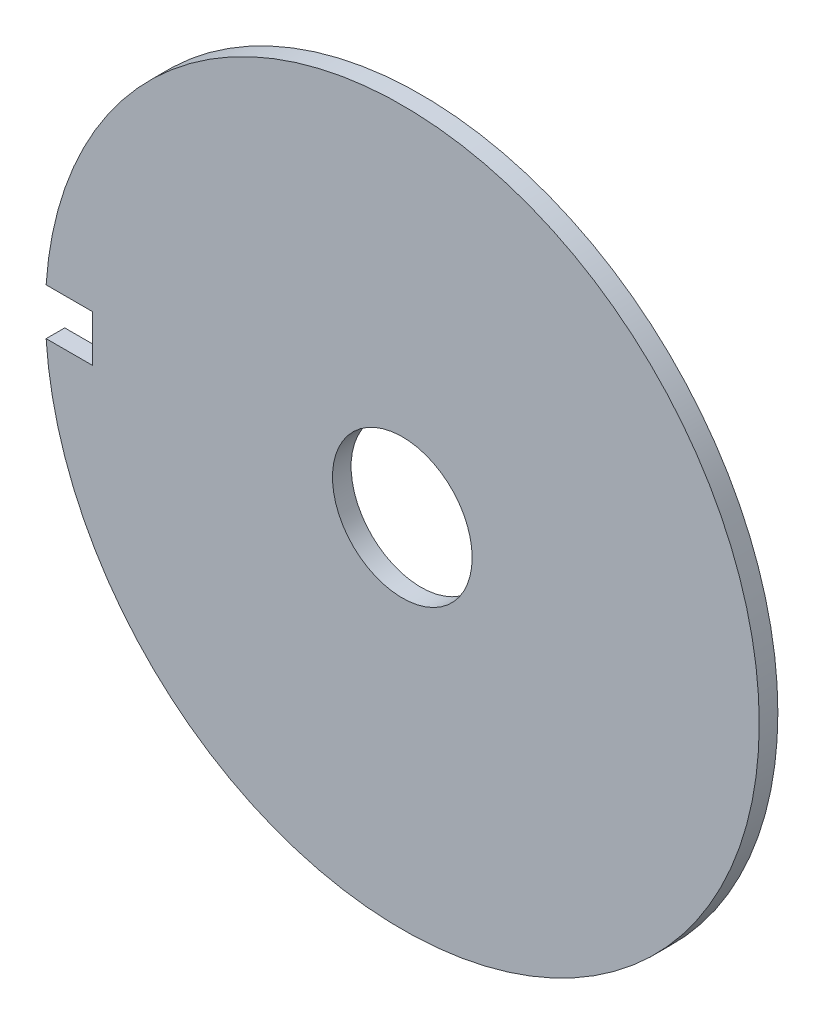
from build123d import *

# Parameters (mm, degrees)
ESQUISSE1_R             = 115
ESQUISSE1_R_2           = 22.5
BOSS_EXTRU_1_DEPTH      = 6
ENL_V_MAT_EXTRU_2_DEPTH = 6


with BuildPart() as part:
    # Esquisse1 → Boss.-Extru.1 (new body)
    with BuildSketch(Plane.XY):
        Circle(ESQUISSE1_R)
        Circle(ESQUISSE1_R_2, mode=Mode.SUBTRACT)
    extrude(amount=BOSS_EXTRU_1_DEPTH)

    # Esquisse2 → Enlèv. mat.-Extru.2 (cut)
    with BuildSketch(Plane.XY.offset(6)):
        Polygon((-114.755174175, 7.5), (-99.755174175, 7.5), (-99.755174175, -7.5), (-114.755174175, -7.5), (-126.610711634, 0), align=None)
    extrude(amount=-ENL_V_MAT_EXTRU_2_DEPTH, mode=Mode.SUBTRACT)


solid = part.part
